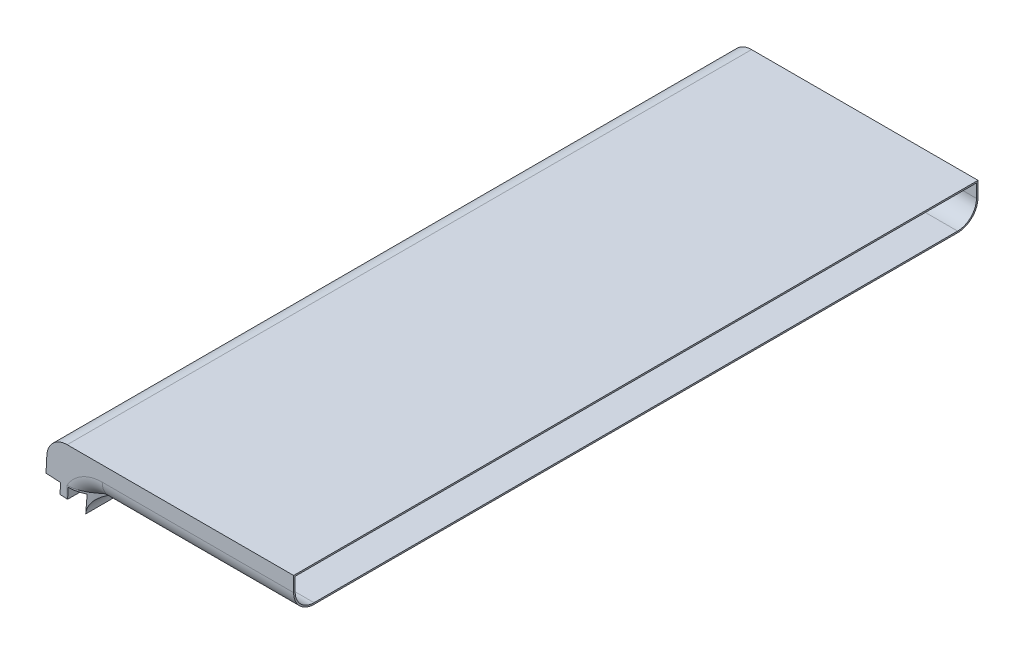
from build123d import *

# Parameters (mm, degrees)
BOSS_EXTRUDE1_DEPTH = 450
FILLET1_R           = 13.4
BOSS_EXTRUDE2_DEPTH = 450
FILLET2_R           = 13.4
CUT_EXTRUDE1_DEPTH  = 451.0000001
SHELL1_T            = -1
BOSS_EXTRUDE3_DEPTH = 450
CUT_EXTRUDE2_DEPTH  = 13.698698186


with BuildPart() as part:
    # Sketch2 → Boss-Extrude1 (new body)
    with BuildSketch(Plane.XY):
        Polygon((0, 0), (162.820860479, 0), (162.820860479, 23.2), (1.215860479, 23.2), align=None)
    extrude(amount=BOSS_EXTRUDE1_DEPTH)

    # Fillet1
    fillet1_edges = [part.edges().sort_by_distance(p)[0] for p in [
        (1.215860479, 23.2, 225),
    ]]
    fillet(fillet1_edges, radius=FILLET1_R)

    # Sketch4 → Boss-Extrude2 (add, through all)
    with BuildSketch(Plane.XY.offset(450)):
        with BuildLine():
            Line((24.166834741, -1.266530141), (23.567700201, -12.698698186))
            ThreePointArc((23.567700201, -12.698698186), (27.725384653, -3.679983428), (36.949335967, 0))
            Line((36.949335967, 0), (0, 0))
            Line((0, 0), (9.586843534, -0.50242518))
            Line((9.586843534, -0.50242518), (9.22049184, -7.492831923))
            Line((9.22049184, -7.492831923), (14.213639514, -7.754511704))
            Line((14.213639514, -7.754511704), (14.579991207, -0.764104961))
            Line((14.579991207, -0.764104961), (24.166834741, -1.266530141))
        make_face()
    extrude(amount=-BOSS_EXTRUDE2_DEPTH)

    # Fillet2
    fillet2_edges = [part.edges().sort_by_distance(p)[0] for p in [
        (27.725384653, -3.679983428, 0),
        (27.725384653, -3.679983428, 450),
        (99.885098223, 0, 450),
        (99.885098223, 0, 0),
    ]]
    fillet(fillet2_edges, radius=FILLET2_R)

    # Sketch5 → Cut-Extrude1 (cut, through all)
    with BuildSketch(Plane.XY):
        with BuildLine():
            Line((24.166834741, -1.266530141), (23.567700201, -12.698698186))
            ThreePointArc((23.567700201, -12.698698186), (27.725384653, -3.679983428), (36.949335967, 0))
            Line((36.949335967, 0), (0, 0))
            Line((0, 0), (9.586843534, -0.50242518))
            Line((9.586843534, -0.50242518), (9.22049184, -7.492831923))
            Line((9.22049184, -7.492831923), (14.213639514, -7.754511704))
            Line((14.213639514, -7.754511704), (14.579991207, -0.764104961))
            Line((14.579991207, -0.764104961), (24.166834741, -1.266530141))
        make_face()
    extrude(amount=CUT_EXTRUDE1_DEPTH, mode=Mode.SUBTRACT)

    # Shell1
    shell1_openings = [part.faces().sort_by_distance(p)[0] for p in [
        (162.820860479, 11.274923044, 225),
    ]]
    offset(amount=SHELL1_T, openings=shell1_openings)

    # Sketch6 → Boss-Extrude3 (add)
    with BuildSketch(Plane.XY):
        with BuildLine():
            Line((24.166834741, -1.266530141), (23.567700201, -12.698698186))
            ThreePointArc((23.567700201, -12.698698186), (27.725384653, -3.679983428), (36.949335967, 0))
            Line((36.949335967, 0), (0, 0))
            Line((0, 0), (9.586843534, -0.50242518))
            Line((9.586843534, -0.50242518), (9.22049184, -7.492831923))
            Line((9.22049184, -7.492831923), (14.213639514, -7.754511704))
            Line((14.213639514, -7.754511704), (14.579991207, -0.764104961))
            Line((14.579991207, -0.764104961), (24.166834741, -1.266530141))
        make_face()
    extrude(amount=BOSS_EXTRUDE3_DEPTH)

    # Sketch7 → Cut-Extrude2 (cut, through all)
    with BuildSketch(Plane.XZ):
        with BuildLine():
            Line((13.739855146, 450), (36.949335967, 450))
            Line((36.949335967, 450), (36.949335967, 436.6))
            add(Edge.make_bspline(
                [(13.739855146, 450), (14.897031698, 450), (16.037346218, 449.888583323), (17.726143963, 449.5782461), (18.285436938, 449.450751492), (19.397111441, 449.150094553), (19.951343846, 448.976153087), (22.667401959, 448.011694289), (24.688899416, 446.937288096), (27.088419743, 445.339458648), (27.560915156, 445.007570641), (28.487586558, 444.326213533), (28.942650844, 443.976156414), (30.286745236, 442.902062513), (31.15469064, 442.154118787), (32.853186658, 440.615831161), (33.683710559, 439.825456971), (35.32594722, 438.223379533), (36.139219776, 437.410115889), (36.949335967, 436.6)],
                knots=[0, 0, 0, 0, 0.125, 0.125, 0.1875, 0.1875, 0.25, 0.25, 0.5, 0.5, 0.5625, 0.5625, 0.625, 0.625, 0.75, 0.75, 0.875, 0.875, 1, 1, 1, 1], degree=3))
        make_face()
        with BuildLine():
            Line((36.949335967, 13.4), (36.949335967, 0))
            Line((36.949335967, 0), (13.739855146, 0))
            add(Edge.make_bspline(
                [(36.949335967, 13.4), (36.139219776, 12.589884111), (35.32594722, 11.776620467), (33.683710559, 10.174543029), (32.853186658, 9.384168839), (31.15469064, 7.845881213), (30.286745236, 7.097937487), (28.942650844, 6.023843586), (28.487586558, 5.673786467), (27.560915156, 4.992429359), (27.088419743, 4.660541352), (24.688899416, 3.062711904), (22.667401959, 1.988305711), (19.951343846, 1.023846913), (19.397111441, 0.849905447), (18.285436938, 0.549248508), (17.726143963, 0.4217539), (16.037346218, 0.111416677), (14.897031698, 0), (13.739855146, 0)],
                knots=[0, 0, 0, 0, 0.125, 0.125, 0.25, 0.25, 0.375, 0.375, 0.4375, 0.4375, 0.5, 0.5, 0.75, 0.75, 0.8125, 0.8125, 0.875, 0.875, 1, 1, 1, 1], degree=3))
        make_face()
    extrude(amount=CUT_EXTRUDE2_DEPTH, mode=Mode.SUBTRACT)


solid = part.part
